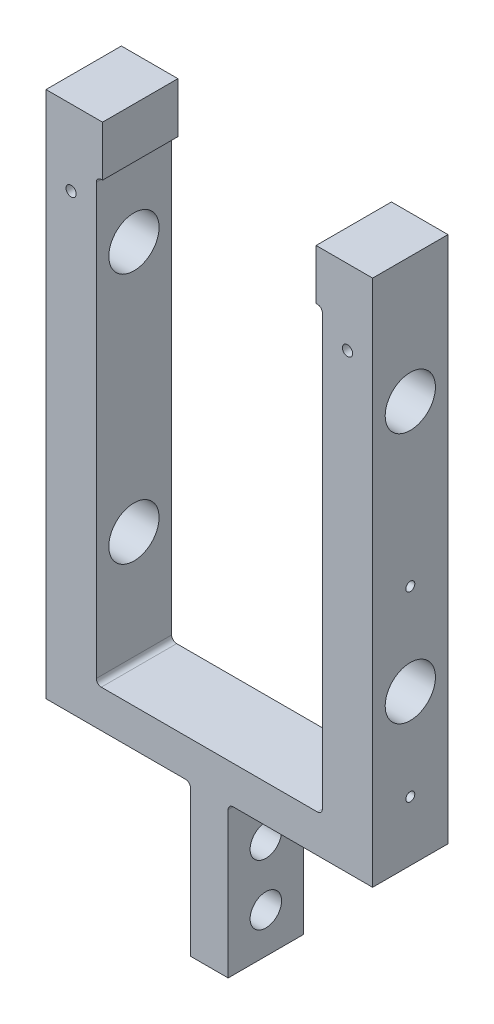
from build123d import *

# Parameters (mm, degrees)
SKETCH1_W                 = 57.15
SKETCH1_H                 = 111.125
BOSS_EXTRUDE1_DEPTH       = 9.525
SKETCH2_R                 = 6.35
CUT_EXTRUDE1_DEPTH        = 83.55
SKETCH4_W                 = 4.7625
SKETCH4_H                 = 19.05
SKETCH4_H_2               = 19.057929795
CUT_EXTRUDE2_DEPTH        = 20.05
F_4_40_TAPPED_HOLE2_D     = 2.2606
F_4_40_TAPPED_HOLE2_DEPTH = 12.7
F_4_40_TAPPED_HOLE2_TIP   = 0.679152758
SKETCH14_W                = 9.525
SKETCH14_H                = 19.05
BOSS_EXTRUDE2_DEPTH       = 19.05
HOLE1_D                   = 7.94512
HOLE1_DEPTH               = 46.0375
HOLE1_TIP                 = 2.386954861
FILLET1_R                 = 1.27
SKETCH17_W                = 53.975
SKETCH17_H                = 12.7
CUT_EXTRUDE3_DEPTH        = 20.05
F_5_40_TAPPED_HOLE1_D     = 2.5781


with BuildPart() as part:
    # Sketch1 → Boss-Extrude1 (new body, symmetric)
    with BuildSketch(Plane.XY):
        Polygon((9.525, 0), (-9.525, 0), (-9.525, 19.05), (-41.275, 19.05), (-41.275, 131.596658994), (-41.275, 152.4), (41.275, 152.4), (41.275, 131.596658994), (41.275, 19.05), (9.525, 19.05), align=None)
        with Locations((0, 84.1375)):
            Rectangle(SKETCH1_W, SKETCH1_H, mode=Mode.SUBTRACT)
    extrude(amount=BOSS_EXTRUDE1_DEPTH, both=True)

    # Sketch2 → Cut-Extrude1 (cut, through all)
    with BuildSketch(Plane.ZY.offset(41.275)):
        with Locations((0, 57.15)):
            Circle(SKETCH2_R)
        with Locations((0, 120.65)):
            Circle(SKETCH2_R)
    extrude(amount=-CUT_EXTRUDE1_DEPTH, mode=Mode.SUBTRACT)

    # Sketch4 → Cut-Extrude2 (cut, through all)
    with BuildSketch(Plane(origin=(0, 0, -9.525), x_dir=(-1, 0, 0), z_dir=(0, 0, -1))):
        with Locations((-7.14375, 9.525)):
            Rectangle(SKETCH4_W, SKETCH4_H)
        with Locations((7.14375, 9.528964897)):
            Rectangle(SKETCH4_W, SKETCH4_H_2)
    extrude(amount=-CUT_EXTRUDE2_DEPTH, mode=Mode.SUBTRACT)

    # #4-40 Tapped Hole2
    with Locations(Plane(origin=(41.275, 0, 0), x_dir=(0, 0, -1), z_dir=(1, 0, 0))):
        with Locations((0, 80.1624), (0, 34.1376)):
            Hole(F_4_40_TAPPED_HOLE2_D / 2, depth=F_4_40_TAPPED_HOLE2_DEPTH)
            with Locations((0, 0, -(F_4_40_TAPPED_HOLE2_DEPTH + F_4_40_TAPPED_HOLE2_TIP / 2))):  # 118° drill point
                Cone(0, F_4_40_TAPPED_HOLE2_D / 2, F_4_40_TAPPED_HOLE2_TIP, mode=Mode.SUBTRACT)

    # Sketch14 → Boss-Extrude2 (add)
    with BuildSketch(Plane.XZ):
        Rectangle(SKETCH14_W, SKETCH14_H)
    extrude(amount=BOSS_EXTRUDE2_DEPTH)

    # Hole1
    with Locations(Plane.ZY.offset(4.7625)):
        with Locations((0, 6.35), (0, -8.89)):
            Hole(HOLE1_D / 2, depth=HOLE1_DEPTH)
            with Locations((0, 0, -(HOLE1_DEPTH + HOLE1_TIP / 2))):  # 118° drill point
                Cone(0, HOLE1_D / 2, HOLE1_TIP, mode=Mode.SUBTRACT)

    # Fillet1
    fillet1_edges = [part.edges().sort_by_distance(p)[0] for p in [
        (28.575, 139.7, 0),
        (-28.575, 139.7, 0),
        (-28.575, 28.575, 0),
        (28.575, 28.575, 0),
        (-4.7625, 19.057929795, 0),
        (4.7625, 19.05, 0),
    ]]
    fillet(fillet1_edges, radius=FILLET1_R)

    # Sketch17 → Cut-Extrude3 (cut, through all)
    with BuildSketch(Plane.XY.offset(9.525)):
        with Locations((0, 146.05)):
            Rectangle(SKETCH17_W, SKETCH17_H)
    extrude(amount=-CUT_EXTRUDE3_DEPTH, mode=Mode.SUBTRACT)

    # #5-40 Tapped Hole1 (through all)
    with Locations(Plane.XY.offset(9.525)):
        with Locations((34.925, 133.35), (-34.925, 133.35)):
            Hole(F_5_40_TAPPED_HOLE1_D / 2)


solid = part.part
